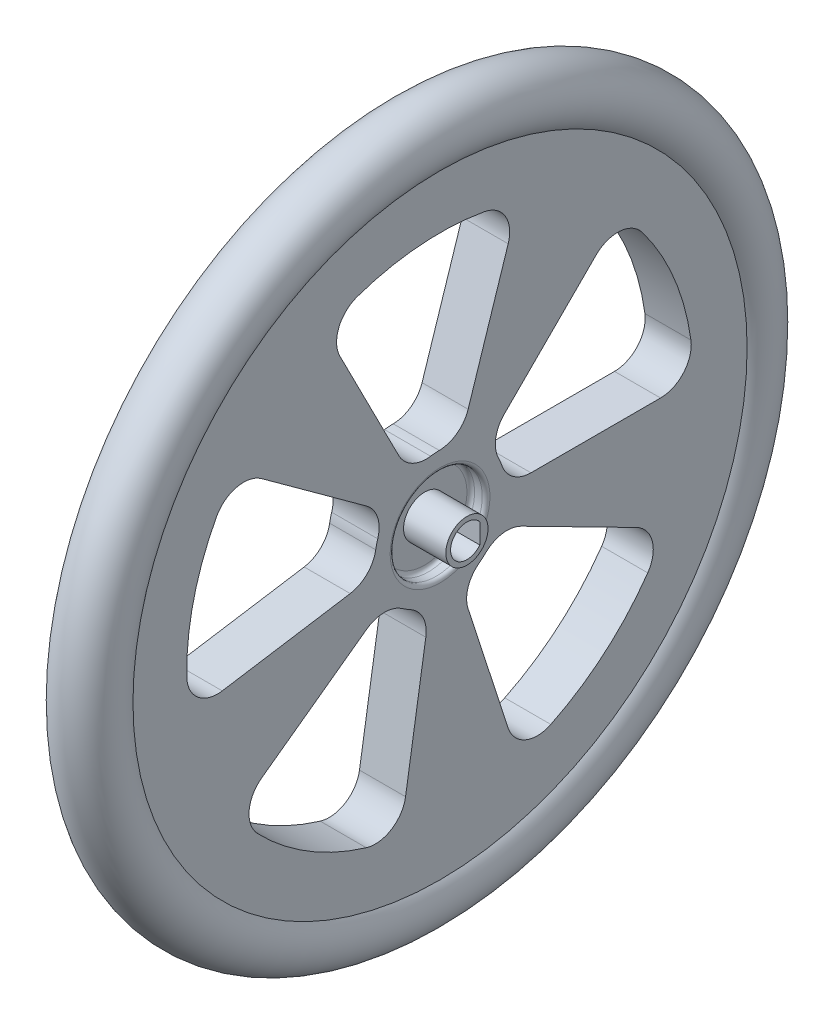
from build123d import *

# Parameters (mm, degrees)
CUT_EXTRUDE1_DEPTH  = 6
CIRPATTERN1_COUNT   = 5
SKETCH8_R           = 2.75
BOSS_EXTRUDE1_DEPTH = 5.5
CUT_EXTRUDE2_REACH  = 9.5


with BuildPart() as part:
    # Sketch3 → Shape_Roue (revolve)
    with BuildSketch(Plane.XY):
        with BuildLine():
            Line((-1, 0), (1, 0))
            Line((1, 0), (1, 5.5))
            ThreePointArc((1, 5.5), (1.146446609, 5.853553391), (1.5, 6))
            Line((1.5, 6), (2.5, 6))
            ThreePointArc((2.5, 6), (2.853553391, 6.146446609), (3, 6.5))
            Line((3, 6.5), (3, 40))
            ThreePointArc((3, 40), (0, 46.645751311), (-3, 40))
            Line((-3, 40), (-3, 6.5))
            ThreePointArc((-3, 6.5), (-2.853553391, 6.146446609), (-2.5, 6))
            Line((-2.5, 6), (-1.5, 6))
            ThreePointArc((-1.5, 6), (-1.146446609, 5.853553391), (-1, 5.5))
            Line((-1, 5.5), (-1, 0))
        make_face()
    revolve(axis=Axis((0, 0, 0), (1, 0, 0)))

    # Sketch6 → Cut-Extrude1 (cut)
    with BuildSketch(Plane(origin=(3, 0, 0), x_dir=(0, 0, -1), z_dir=(1, 0, 0))):
        with BuildLine():
            Line((8.374067112, 8.374067112), (20.310096012, 20.310096012))
            ThreePointArc((20.310096012, 20.310096012), (23.415046761, 21.472099275), (26.330043569, 19.892933561))
            ThreePointArc((26.330043569, 19.892933561), (30.488024573, 12.628553268), (32.684580575, 4.551724138))
            ThreePointArc((32.684580575, 4.551724138), (31.740005351, 1.373871343), (28.722813233, 0))
            Line((28.722813233, 0), (11.842719282, 0))
            ThreePointArc((11.842719282, 0), (9.510338524, 0.750384638), (8.053049112, 2.72))
            ThreePointArc((8.053049112, 2.72), (7.852976026, 3.252809175), (7.617696081, 3.771035191))
            ThreePointArc((7.617696081, 3.771035191), (7.255426928, 6.194222796), (8.374067112, 8.374067112))
        make_face()
    cut_extrude1 = extrude(amount=-CUT_EXTRUDE1_DEPTH, mode=Mode.SUBTRACT)

    # CirPattern1: Cut-Extrude1 ×5 about axis
    cirpattern1_axis = Axis((0, 0, 0), (1, 0, 0))
    for i in range(1, CIRPATTERN1_COUNT):
        add(cut_extrude1.rotate(cirpattern1_axis, i * 360 / CIRPATTERN1_COUNT), mode=Mode.SUBTRACT)

    # Sketch8 → Boss-Extrude1 (add)
    with BuildSketch(Plane(origin=(1, 0, 0), x_dir=(0, 0, -1), z_dir=(1, 0, 0))):
        Circle(SKETCH8_R)
    extrude(amount=BOSS_EXTRUDE1_DEPTH)

    # Sketch7 → Cut-Extrude2 (cut, up to next)
    with BuildSketch(Plane(origin=(-1, 0, 0), x_dir=(0, 0, -1), z_dir=(1, 0, 0)), mode=Mode.PRIVATE) as cut_extrude2_sk1:
        with BuildLine():
            Line((1.675, 1.307669683), (1.675, -1.307669683))
            ThreePointArc((1.675, -1.307669683), (-2.125, 0), (1.675, 1.307669683))
        make_face()
    cut_extrude2_tool1 = extrude(cut_extrude2_sk1.sketch, amount=CUT_EXTRUDE2_REACH, mode=Mode.PRIVATE) & part.part
    add(cut_extrude2_tool1.solids().sort_by_distance((-1, 0, 0.111388))[0], mode=Mode.SUBTRACT)


solid = part.part
